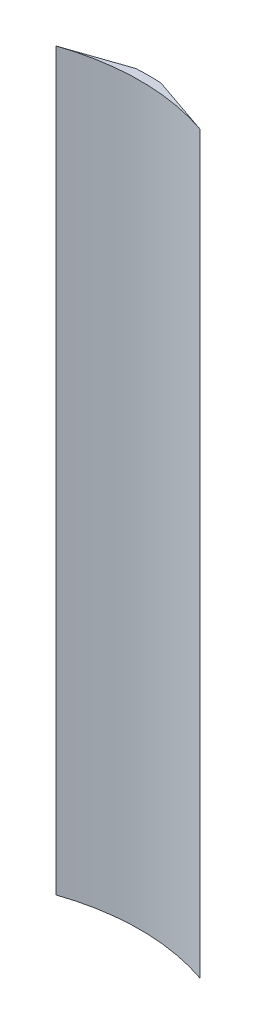
from build123d import *

# Parameters (mm, degrees)
BOSS_EXTRUDE1_DEPTH = 133.35


with BuildPart() as part:
    # Sketch2 → Boss-Extrude1 (new body)
    with BuildSketch(Plane(origin=(0, 0, 0), x_dir=(1, 0, 0), z_dir=(0, 1, 0))):
        with BuildLine():
            Line((-2.255667061, 41.658476285), (-13.036564626, 37.955571485))
            ThreePointArc((-13.036564626, 37.955571485), (0.001030283, 40.131999987), (13.038513426, 37.954902077))
            Line((13.038513426, 37.954902077), (2.257806, 41.658360413))
            ThreePointArc((2.257806, 41.658360413), (0.001071038, 41.719499986), (-2.255667061, 41.658476285))
        make_face()
    extrude(amount=BOSS_EXTRUDE1_DEPTH)


solid = part.part
